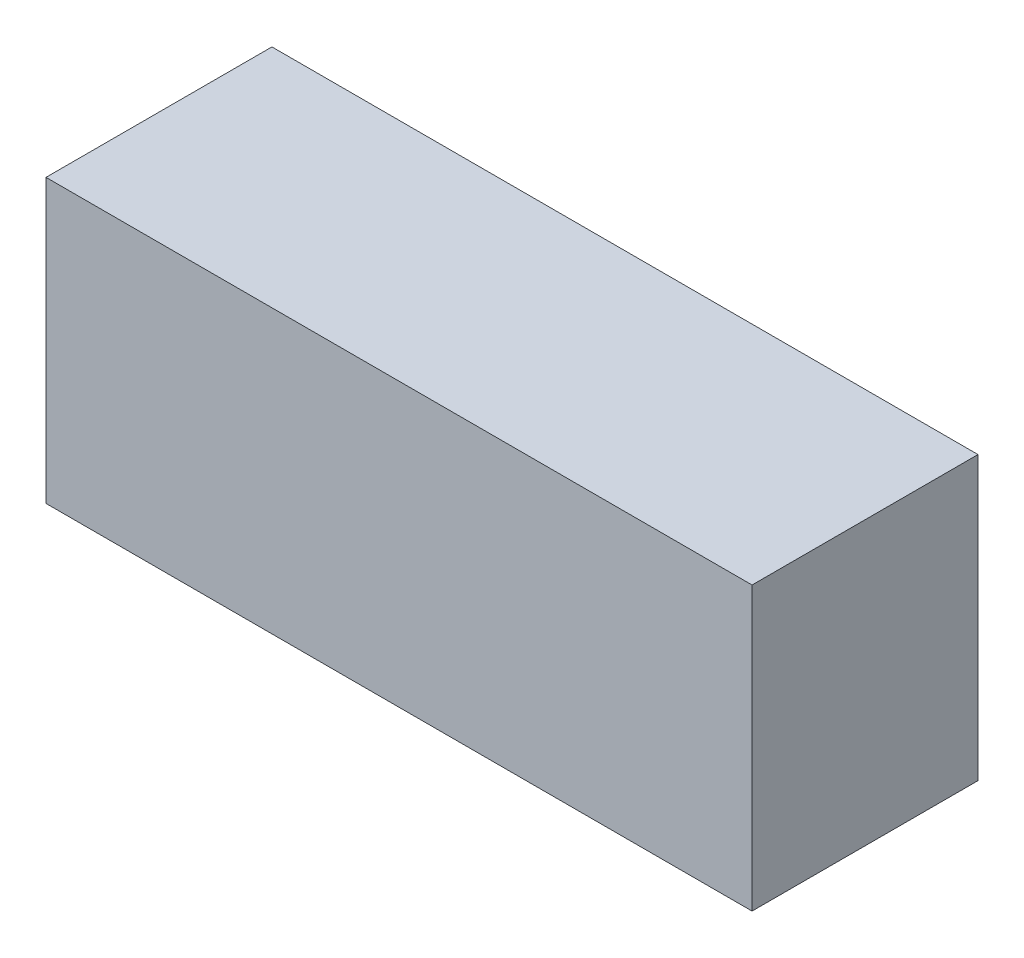
from build123d import *

# Parameters (mm, degrees)
SKETCH1_W           = 100
SKETCH1_H           = 40
BOSS_EXTRUDE1_DEPTH = 32


with BuildPart() as part:
    # Sketch1 → Boss-Extrude1 (new body)
    with BuildSketch(Plane.XY):
        Rectangle(SKETCH1_W, SKETCH1_H)
    extrude(amount=BOSS_EXTRUDE1_DEPTH)


solid = part.part
